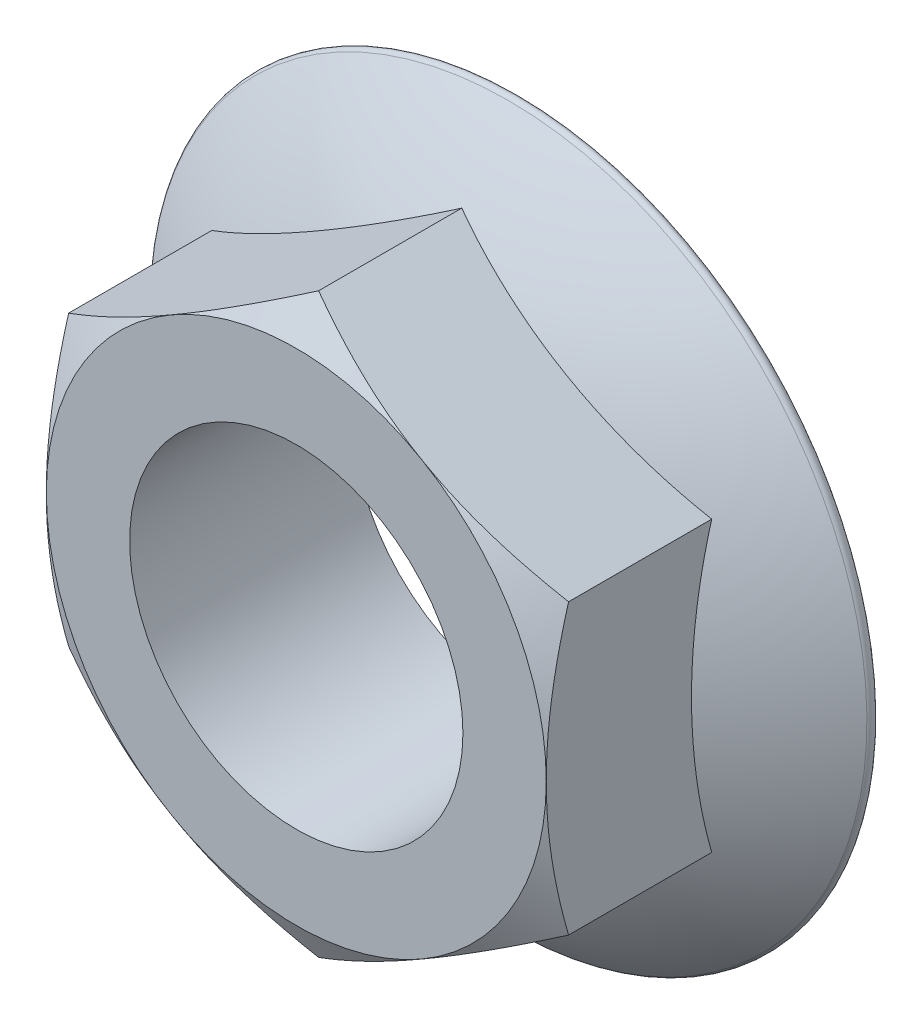
from build123d import *

# Parameters (mm, degrees)
BOSS_EXTRUDE1_DEPTH = 20
SKETCH3_OUTSIDE_W   = 154.97
SKETCH3_OUTSIDE_H   = 154.97
SKETCH3_OUTSIDE_R   = 22.5
CUT_EXTRUDE1_DEPTH  = 20
CUT_EXTRUDE1_TAPER  = 60
CUT_EXTRUDE2_REACH  = 22
SKETCH4_R           = 15


with BuildPart() as part:
    # Sketch1 → Boss-Extrude1 (new body)
    with BuildSketch(Plane.XY):
        Polygon((0, 25.980762114), (-22.5, 12.990381057), (-22.5, -12.990381057), (0, -25.980762114), (22.5, -12.990381057), (22.5, 12.990381057), align=None)
    extrude(amount=BOSS_EXTRUDE1_DEPTH)

    # Sketch2 → Revolve2 (revolve)
    with BuildSketch(Plane(origin=(0, 0, 0), x_dir=(0, 0, -1), z_dir=(1, 0, 0))):
        with BuildLine():
            Line((0, 0), (-12, 0))
            ThreePointArc((-12, 0), (-9.145772075, -17.058051419), (-0.894027207, -32.257802794))
            ThreePointArc((-0.894027207, -32.257802794), (-0.337232687, -32.42276506), (0, -31.95))
            Line((0, -31.95), (0, 0))
        make_face()
    revolve(axis=Axis((0, 0, 0), (0, 0, 1)))

    # Sketch3 outside → Cut-Extrude1 (cut)
    with BuildSketch(Plane.XY.offset(20)):
        Rectangle(SKETCH3_OUTSIDE_W, SKETCH3_OUTSIDE_H)
        Circle(SKETCH3_OUTSIDE_R, mode=Mode.SUBTRACT)
    extrude(amount=-CUT_EXTRUDE1_DEPTH, taper=CUT_EXTRUDE1_TAPER, mode=Mode.SUBTRACT)

    # Sketch4 → Cut-Extrude2 (cut, up to next)
    with BuildSketch(Plane.XY.offset(20), mode=Mode.PRIVATE) as cut_extrude2_sk1:
        Circle(SKETCH4_R)
    cut_extrude2_tool1 = extrude(cut_extrude2_sk1.sketch, amount=-CUT_EXTRUDE2_REACH, mode=Mode.PRIVATE) & part.part
    add(cut_extrude2_tool1.solids().sort_by_distance((0, 0, 20))[0], mode=Mode.SUBTRACT)


solid = part.part
